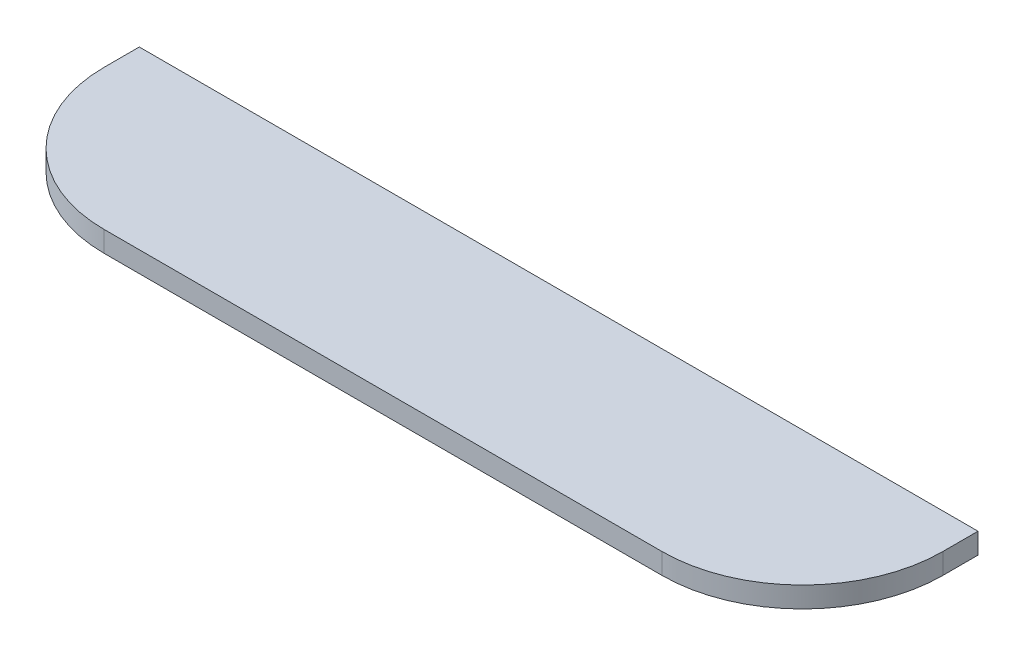
from build123d import *

# Parameters (mm, degrees)
SKETCH1_W           = 121.33
SKETCH1_H           = 3
BOSS_EXTRUDE1_DEPTH = 25.4
FILLET1_R           = 20.32


with BuildPart() as part:
    # Sketch1 → Boss-Extrude1 (new body)
    with BuildSketch(Plane.XY):
        Rectangle(SKETCH1_W, SKETCH1_H)
    extrude(amount=BOSS_EXTRUDE1_DEPTH)

    # Fillet1
    fillet1_edges = [part.edges().sort_by_distance(p)[0] for p in [
        (-60.665, 0, 25.4),
        (60.665, 0, 25.4),
    ]]
    fillet(fillet1_edges, radius=FILLET1_R)


solid = part.part
